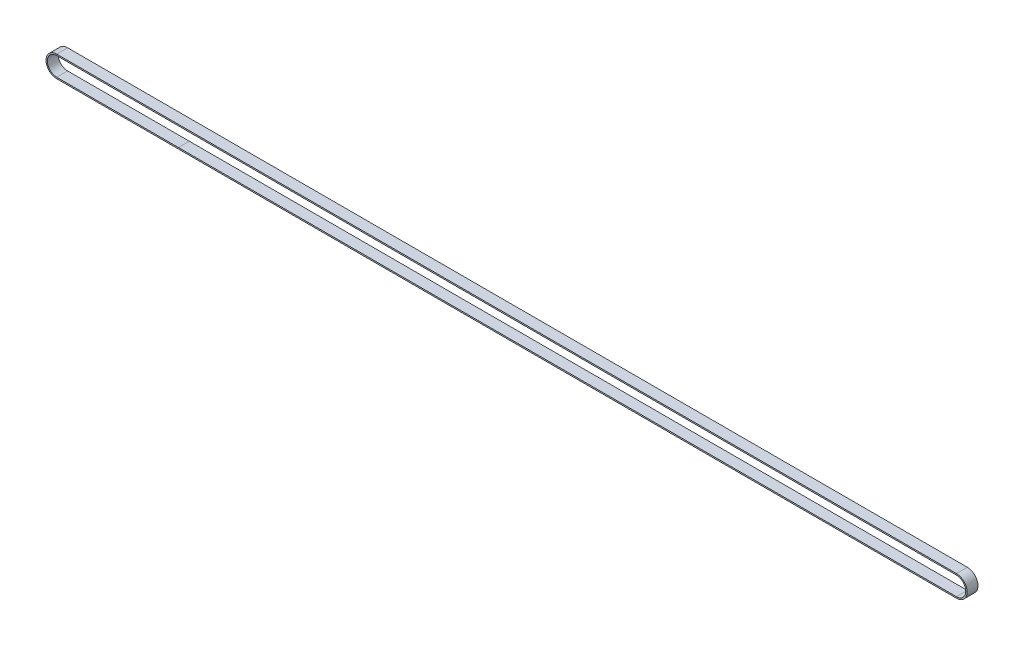
from build123d import *

# Parameters (mm, degrees)
BOSS_EXTRUDE1_DEPTH = 6
CUT_EXTRUDE_2_DEPTH = 7


with BuildPart() as part:
    # Sketch1 → Boss-Extrude1 (new body)
    with BuildSketch(Plane.XY):
        with BuildLine():
            Line((-149.09186475, 9.090711875), (346.90813525, 9.090711875))
            ThreePointArc((346.90813525, 9.090711875), (352.80813525, 3.190711875), (346.90813525, -2.709288125))
            Line((346.90813525, -2.709288125), (-149.09186475, -2.709288125))
            ThreePointArc((-149.09186475, -2.709288125), (-154.99186475, 3.190711875), (-149.09186475, 9.090711875))
        make_face()
        with BuildLine():
            Line((-148.86218671, -1.959304919), (-148.987691743, -1.959304919))
            ThreePointArc((-148.987691743, -1.959304919), (-154.24186475, 3.085711875), (-149.19686475, 8.340711875))
            Line((-149.19686475, 8.340711875), (-148.86218671, 8.34072867))
            ThreePointArc((-148.86218671, 8.34072867), (-148.782434101, 8.302805538), (-148.722766674, 8.237809494))
            ThreePointArc((-148.722766674, 8.237809494), (-148.665742437, 8.11963083), (-148.633605814, 7.992409772))
            ThreePointArc((-148.633605814, 7.992409772), (-148.030521792, 7.471711105), (-147.427440071, 7.992412438))
            ThreePointArc((-147.427440071, 7.992412438), (-147.395304056, 8.119633592), (-147.338280406, 8.237812478))
            ThreePointArc((-147.338280406, 8.237812478), (-147.278614273, 8.302808129), (-147.198941265, 8.340711875))
            Line((-147.198941265, 8.340711875), (-146.862186774, 8.34072867))
            ThreePointArc((-146.862186774, 8.34072867), (-146.782434165, 8.302805538), (-146.722766738, 8.237809494))
            ThreePointArc((-146.722766738, 8.237809494), (-146.665742501, 8.11963083), (-146.633605878, 7.992409772))
            ThreePointArc((-146.633605878, 7.992409772), (-146.030521856, 7.471711105), (-145.427440135, 7.992412438))
            ThreePointArc((-145.427440135, 7.992412438), (-145.395304121, 8.119633592), (-145.33828047, 8.237812478))
            ThreePointArc((-145.33828047, 8.237812478), (-145.278614337, 8.302808129), (-145.198941329, 8.340711875))
            Line((-145.198941329, 8.340711875), (-144.862186838, 8.34072867))
            ThreePointArc((-144.862186838, 8.34072867), (-144.78243423, 8.302805538), (-144.722766802, 8.237809494))
            ThreePointArc((-144.722766802, 8.237809494), (-144.665742565, 8.11963083), (-144.633605942, 7.992409772))
            ThreePointArc((-144.633605942, 7.992409772), (-144.03052192, 7.471711105), (-143.427440199, 7.992412438))
            ThreePointArc((-143.427440199, 7.992412438), (-143.395304185, 8.119633592), (-143.338280535, 8.237812478))
            ThreePointArc((-143.338280535, 8.237812478), (-143.278614401, 8.302808129), (-143.198941393, 8.340711875))
            Line((-143.198941393, 8.340711875), (-142.862186903, 8.34072867))
            ThreePointArc((-142.862186903, 8.34072867), (-142.782434294, 8.302805538), (-142.722766866, 8.237809494))
            ThreePointArc((-142.722766866, 8.237809494), (-142.665742629, 8.11963083), (-142.633606007, 7.992409772))
            ThreePointArc((-142.633606007, 7.992409772), (-142.030521984, 7.471711105), (-141.427440263, 7.992412438))
            ThreePointArc((-141.427440263, 7.992412438), (-141.395304249, 8.119633592), (-141.338280599, 8.237812478))
            ThreePointArc((-141.338280599, 8.237812478), (-141.278614465, 8.302808129), (-141.198941458, 8.340711875))
            Line((-141.198941458, 8.340711875), (-140.862186967, 8.34072867))
            ThreePointArc((-140.862186967, 8.34072867), (-140.782434358, 8.302805538), (-140.722766931, 8.237809494))
            ThreePointArc((-140.722766931, 8.237809494), (-140.665742694, 8.11963083), (-140.633606071, 7.992409772))
            ThreePointArc((-140.633606071, 7.992409772), (-140.030522048, 7.471711105), (-139.427440328, 7.992412438))
            ThreePointArc((-139.427440328, 7.992412438), (-139.395304313, 8.119633592), (-139.338280663, 8.237812478))
            ThreePointArc((-139.338280663, 8.237812478), (-139.27861453, 8.302808129), (-139.198941522, 8.340711875))
            Line((-139.198941522, 8.340711875), (-138.862187031, 8.34072867))
            ThreePointArc((-138.862187031, 8.34072867), (-138.782434422, 8.302805538), (-138.722766995, 8.237809494))
            ThreePointArc((-138.722766995, 8.237809494), (-138.665742758, 8.11963083), (-138.633606135, 7.992409772))
            ThreePointArc((-138.633606135, 7.992409772), (-138.030522113, 7.471711105), (-137.427440392, 7.992412438))
            ThreePointArc((-137.427440392, 7.992412438), (-137.395304377, 8.119633592), (-137.338280727, 8.237812478))
            ThreePointArc((-137.338280727, 8.237812478), (-137.278614594, 8.302808129), (-137.198941586, 8.340711875))
            Line((-137.198941586, 8.340711875), (-136.862187095, 8.34072867))
            ThreePointArc((-136.862187095, 8.34072867), (-136.782434486, 8.302805538), (-136.722767059, 8.237809494))
            ThreePointArc((-136.722767059, 8.237809494), (-136.665742822, 8.11963083), (-136.633606199, 7.992409772))
            ThreePointArc((-136.633606199, 7.992409772), (-136.030522177, 7.471711105), (-135.427440456, 7.992412438))
            ThreePointArc((-135.427440456, 7.992412438), (-135.395304442, 8.119633592), (-135.338280792, 8.237812478))
            ThreePointArc((-135.338280792, 8.237812478), (-135.278614658, 8.302808129), (-135.19894165, 8.340711875))
            Line((-135.19894165, 8.340711875), (-134.86218716, 8.34072867))
            ThreePointArc((-134.86218716, 8.34072867), (-134.782434551, 8.302805538), (-134.722767123, 8.237809494))
            ThreePointArc((-134.722767123, 8.237809494), (-134.665742886, 8.11963083), (-134.633606264, 7.992409772))
            ThreePointArc((-134.633606264, 7.992409772), (-134.030522241, 7.471711105), (-133.42744052, 7.992412438))
            ThreePointArc((-133.42744052, 7.992412438), (-133.395304506, 8.119633592), (-133.338280856, 8.237812478))
            ThreePointArc((-133.338280856, 8.237812478), (-133.278614722, 8.302808129), (-133.198941715, 8.340711875))
            Line((-133.198941715, 8.340711875), (-132.862187224, 8.34072867))
            ThreePointArc((-132.862187224, 8.34072867), (-132.782434615, 8.302805538), (-132.722767187, 8.237809494))
            ThreePointArc((-132.722767187, 8.237809494), (-132.665742951, 8.11963083), (-132.633606328, 7.992409772))
            ThreePointArc((-132.633606328, 7.992409772), (-132.030522305, 7.471711105), (-131.427440585, 7.992412438))
            ThreePointArc((-131.427440585, 7.992412438), (-131.39530457, 8.119633592), (-131.33828092, 8.237812478))
            ThreePointArc((-131.33828092, 8.237812478), (-131.278614786, 8.302808129), (-131.198941779, 8.340711875))
            Line((-131.198941779, 8.340711875), (-130.862187288, 8.34072867))
            ThreePointArc((-130.862187288, 8.34072867), (-130.782434679, 8.302805538), (-130.722767252, 8.237809494))
            ThreePointArc((-130.722767252, 8.237809494), (-130.665743015, 8.11963083), (-130.633606392, 7.992409772))
            ThreePointArc((-130.633606392, 7.992409772), (-130.03052237, 7.471711105), (-129.427440649, 7.992412438))
            ThreePointArc((-129.427440649, 7.992412438), (-129.395304634, 8.119633592), (-129.338280984, 8.237812478))
            ThreePointArc((-129.338280984, 8.237812478), (-129.278614851, 8.302808129), (-129.198941843, 8.340711875))
            Line((-129.198941843, 8.340711875), (-128.862187352, 8.34072867))
            ThreePointArc((-128.862187352, 8.34072867), (-128.782434743, 8.302805538), (-128.722767316, 8.237809494))
            ThreePointArc((-128.722767316, 8.237809494), (-128.665743079, 8.11963083), (-128.633606456, 7.992409772))
            ThreePointArc((-128.633606456, 7.992409772), (-128.030522434, 7.471711105), (-127.427440713, 7.992412438))
            ThreePointArc((-127.427440713, 7.992412438), (-127.395304699, 8.119633592), (-127.338281048, 8.237812478))
            ThreePointArc((-127.338281048, 8.237812478), (-127.278614915, 8.302808129), (-127.198941907, 8.340711875))
            Line((-127.198941907, 8.340711875), (-126.862187417, 8.34072867))
            ThreePointArc((-126.862187417, 8.34072867), (-126.782434808, 8.302805538), (-126.72276738, 8.237809494))
            ThreePointArc((-126.72276738, 8.237809494), (-126.665743143, 8.11963083), (-126.63360652, 7.992409772))
            ThreePointArc((-126.63360652, 7.992409772), (-126.030522498, 7.471711105), (-125.427440777, 7.992412438))
            ThreePointArc((-125.427440777, 7.992412438), (-125.395304763, 8.119633592), (-125.338281113, 8.237812478))
            ThreePointArc((-125.338281113, 8.237812478), (-125.278614979, 8.302808129), (-125.198941972, 8.340711875))
            Line((-125.198941972, 8.340711875), (-124.862187481, 8.34072867))
            ThreePointArc((-124.862187481, 8.34072867), (-124.782434872, 8.302805538), (-124.722767444, 8.237809494))
            ThreePointArc((-124.722767444, 8.237809494), (-124.665743208, 8.11963083), (-124.633606585, 7.992409772))
            ThreePointArc((-124.633606585, 7.992409772), (-124.030522562, 7.471711105), (-123.427440841, 7.992412438))
            ThreePointArc((-123.427440841, 7.992412438), (-123.395304827, 8.119633592), (-123.338281177, 8.237812478))
            ThreePointArc((-123.338281177, 8.237812478), (-123.278615043, 8.302808129), (-123.198942036, 8.340711875))
            Line((-123.198942036, 8.340711875), (-122.862187545, 8.34072867))
            ThreePointArc((-122.862187545, 8.34072867), (-122.782434936, 8.302805538), (-122.722767509, 8.237809494))
            ThreePointArc((-122.722767509, 8.237809494), (-122.665743272, 8.11963083), (-122.633606649, 7.992409772))
            ThreePointArc((-122.633606649, 7.992409772), (-122.030522627, 7.471711105), (-121.427440906, 7.992412438))
            ThreePointArc((-121.427440906, 7.992412438), (-121.395304891, 8.119633592), (-121.338281241, 8.237812478))
            ThreePointArc((-121.338281241, 8.237812478), (-121.278615108, 8.302808129), (-121.1989421, 8.340711875))
            Line((-121.1989421, 8.340711875), (-120.862187609, 8.34072867))
            ThreePointArc((-120.862187609, 8.34072867), (-120.782435, 8.302805538), (-120.722767573, 8.237809494))
            ThreePointArc((-120.722767573, 8.237809494), (-120.665743336, 8.11963083), (-120.633606713, 7.992409772))
            ThreePointArc((-120.633606713, 7.992409772), (-120.030522691, 7.471711105), (-119.42744097, 7.992412438))
            ThreePointArc((-119.42744097, 7.992412438), (-119.395304956, 8.119633592), (-119.338281305, 8.237812478))
            ThreePointArc((-119.338281305, 8.237812478), (-119.278615172, 8.302808129), (-119.198942164, 8.340711875))
            Line((-119.198942164, 8.340711875), (-118.862187673, 8.34072867))
            ThreePointArc((-118.862187673, 8.34072867), (-118.782435064, 8.302805538), (-118.722767637, 8.237809494))
            ThreePointArc((-118.722767637, 8.237809494), (-118.6657434, 8.11963083), (-118.633606777, 7.992409772))
            ThreePointArc((-118.633606777, 7.992409772), (-118.030522755, 7.471711105), (-117.427441034, 7.992412438))
            ThreePointArc((-117.427441034, 7.992412438), (-117.39530502, 8.119633592), (-117.33828137, 8.237812478))
            ThreePointArc((-117.33828137, 8.237812478), (-117.278615236, 8.302808129), (-117.198942228, 8.340711875))
            Line((-117.198942228, 8.340711875), (-116.862187738, 8.34072867))
            ThreePointArc((-116.862187738, 8.34072867), (-116.782435129, 8.302805538), (-116.722767701, 8.237809494))
            ThreePointArc((-116.722767701, 8.237809494), (-116.665743464, 8.11963083), (-116.633606842, 7.992409772))
            ThreePointArc((-116.633606842, 7.992409772), (-116.030522819, 7.471711105), (-115.427441098, 7.992412438))
            ThreePointArc((-115.427441098, 7.992412438), (-115.395305084, 8.119633592), (-115.338281434, 8.237812478))
            ThreePointArc((-115.338281434, 8.237812478), (-115.2786153, 8.302808129), (-115.198942293, 8.340711875))
            Line((-115.198942293, 8.340711875), (-114.862187802, 8.34072867))
            ThreePointArc((-114.862187802, 8.34072867), (-114.782435193, 8.302805538), (-114.722767766, 8.237809494))
            ThreePointArc((-114.722767766, 8.237809494), (-114.665743529, 8.11963083), (-114.633606906, 7.992409772))
            ThreePointArc((-114.633606906, 7.992409772), (-114.030522883, 7.471711105), (-113.427441163, 7.992412438))
            ThreePointArc((-113.427441163, 7.992412438), (-113.395305148, 8.119633592), (-113.338281498, 8.237812478))
            ThreePointArc((-113.338281498, 8.237812478), (-113.278615364, 8.302808129), (-113.198942357, 8.340711875))
            Line((-113.198942357, 8.340711875), (-112.862187866, 8.34072867))
            ThreePointArc((-112.862187866, 8.34072867), (-112.782435257, 8.302805538), (-112.72276783, 8.237809494))
            ThreePointArc((-112.72276783, 8.237809494), (-112.665743593, 8.11963083), (-112.63360697, 7.992409772))
            ThreePointArc((-112.63360697, 7.992409772), (-112.030522948, 7.471711105), (-111.427441227, 7.992412438))
            ThreePointArc((-111.427441227, 7.992412438), (-111.395305212, 8.119633592), (-111.338281562, 8.237812478))
            ThreePointArc((-111.338281562, 8.237812478), (-111.278615429, 8.302808129), (-111.198942421, 8.340711875))
            Line((-111.198942421, 8.340711875), (-110.86218793, 8.34072867))
            ThreePointArc((-110.86218793, 8.34072867), (-110.782435321, 8.302805538), (-110.722767894, 8.237809494))
            ThreePointArc((-110.722767894, 8.237809494), (-110.665743657, 8.11963083), (-110.633607034, 7.992409772))
            ThreePointArc((-110.633607034, 7.992409772), (-110.030523012, 7.471711105), (-109.427441291, 7.992412438))
            ThreePointArc((-109.427441291, 7.992412438), (-109.395305277, 8.119633592), (-109.338281627, 8.237812478))
            ThreePointArc((-109.338281627, 8.237812478), (-109.278615493, 8.302808129), (-109.198942485, 8.340711875))
            Line((-109.198942485, 8.340711875), (-108.862187995, 8.34072867))
            ThreePointArc((-108.862187995, 8.34072867), (-108.782435386, 8.302805538), (-108.722767958, 8.237809494))
            ThreePointArc((-108.722767958, 8.237809494), (-108.665743721, 8.11963083), (-108.633607098, 7.992409772))
            ThreePointArc((-108.633607098, 7.992409772), (-108.030523076, 7.471711105), (-107.427441355, 7.992412438))
            ThreePointArc((-107.427441355, 7.992412438), (-107.395305341, 8.119633592), (-107.338281691, 8.237812478))
            ThreePointArc((-107.338281691, 8.237812478), (-107.278615557, 8.302808129), (-107.19894255, 8.340711875))
            Line((-107.19894255, 8.340711875), (-106.862188059, 8.34072867))
            ThreePointArc((-106.862188059, 8.34072867), (-106.78243545, 8.302805538), (-106.722768022, 8.237809494))
            ThreePointArc((-106.722768022, 8.237809494), (-106.665743786, 8.11963083), (-106.633607163, 7.992409772))
            ThreePointArc((-106.633607163, 7.992409772), (-106.03052314, 7.471711105), (-105.42744142, 7.992412438))
            ThreePointArc((-105.42744142, 7.992412438), (-105.395305405, 8.119633592), (-105.338281755, 8.237812478))
            ThreePointArc((-105.338281755, 8.237812478), (-105.278615621, 8.302808129), (-105.198942614, 8.340711875))
            Line((-105.198942614, 8.340711875), (-104.862188123, 8.34072867))
            ThreePointArc((-104.862188123, 8.34072867), (-104.782435514, 8.302805538), (-104.722768087, 8.237809494))
            ThreePointArc((-104.722768087, 8.237809494), (-104.66574385, 8.11963083), (-104.633607227, 7.992409772))
            ThreePointArc((-104.633607227, 7.992409772), (-104.030523205, 7.471711105), (-103.427441484, 7.992412438))
            ThreePointArc((-103.427441484, 7.992412438), (-103.395305469, 8.119633592), (-103.338281819, 8.237812478))
            ThreePointArc((-103.338281819, 8.237812478), (-103.278615686, 8.302808129), (-103.198942678, 8.340711875))
            Line((-103.198942678, 8.340711875), (-102.862188187, 8.34072867))
            ThreePointArc((-102.862188187, 8.34072867), (-102.782435578, 8.302805538), (-102.722768151, 8.237809494))
            ThreePointArc((-102.722768151, 8.237809494), (-102.665743914, 8.11963083), (-102.633607291, 7.992409772))
            ThreePointArc((-102.633607291, 7.992409772), (-102.030523269, 7.471711105), (-101.427441548, 7.992412438))
            ThreePointArc((-101.427441548, 7.992412438), (-101.395305534, 8.119633592), (-101.338281883, 8.237812478))
            ThreePointArc((-101.338281883, 8.237812478), (-101.27861575, 8.302808129), (-101.198942742, 8.340711875))
            Line((-101.198942742, 8.340711875), (-100.862188251, 8.34072867))
            ThreePointArc((-100.862188251, 8.34072867), (-100.782435643, 8.302805538), (-100.722768215, 8.237809494))
            ThreePointArc((-100.722768215, 8.237809494), (-100.665743978, 8.11963083), (-100.633607355, 7.992409772))
            ThreePointArc((-100.633607355, 7.992409772), (-100.030523333, 7.471711105), (-99.427441612, 7.992412438))
            ThreePointArc((-99.427441612, 7.992412438), (-99.395305598, 8.119633592), (-99.338281948, 8.237812478))
            ThreePointArc((-99.338281948, 8.237812478), (-99.278615814, 8.302808129), (-99.198942806, 8.340711875))
            Line((-99.198942806, 8.340711875), (-98.862188316, 8.34072867))
            ThreePointArc((-98.862188316, 8.34072867), (-98.782435707, 8.302805538), (-98.722768279, 8.237809494))
            ThreePointArc((-98.722768279, 8.237809494), (-98.665744042, 8.11963083), (-98.63360742, 7.992409772))
            ThreePointArc((-98.63360742, 7.992409772), (-98.030523397, 7.471711105), (-97.427441676, 7.992412438))
            ThreePointArc((-97.427441676, 7.992412438), (-97.395305662, 8.119633592), (-97.338282012, 8.237812478))
            ThreePointArc((-97.338282012, 8.237812478), (-97.278615878, 8.302808129), (-97.198942871, 8.340711875))
            Line((-97.198942871, 8.340711875), (-96.86218838, 8.34072867))
            ThreePointArc((-96.86218838, 8.34072867), (-96.782435771, 8.302805538), (-96.722768344, 8.237809494))
            ThreePointArc((-96.722768344, 8.237809494), (-96.665744107, 8.11963083), (-96.633607484, 7.992409772))
            ThreePointArc((-96.633607484, 7.992409772), (-96.030523461, 7.471711105), (-95.427441741, 7.992412438))
            ThreePointArc((-95.427441741, 7.992412438), (-95.395305726, 8.119633592), (-95.338282076, 8.237812478))
            ThreePointArc((-95.338282076, 8.237812478), (-95.278615943, 8.302808129), (-95.198942935, 8.340711875))
            Line((-95.198942935, 8.340711875), (-94.862188444, 8.34072867))
            ThreePointArc((-94.862188444, 8.34072867), (-94.782435835, 8.302805538), (-94.722768408, 8.237809494))
            ThreePointArc((-94.722768408, 8.237809494), (-94.665744171, 8.11963083), (-94.633607548, 7.992409772))
            ThreePointArc((-94.633607548, 7.992409772), (-94.030523526, 7.471711105), (-93.427441805, 7.992412438))
            ThreePointArc((-93.427441805, 7.992412438), (-93.39530579, 8.119633592), (-93.33828214, 8.237812478))
            ThreePointArc((-93.33828214, 8.237812478), (-93.278616007, 8.302808129), (-93.198942999, 8.340711875))
            Line((-93.198942999, 8.340711875), (-92.862188508, 8.34072867))
            ThreePointArc((-92.862188508, 8.34072867), (-92.782435899, 8.302805538), (-92.722768472, 8.237809494))
            ThreePointArc((-92.722768472, 8.237809494), (-92.665744235, 8.11963083), (-92.633607612, 7.992409772))
            ThreePointArc((-92.633607612, 7.992409772), (-92.03052359, 7.471711105), (-91.427441869, 7.992412438))
            ThreePointArc((-91.427441869, 7.992412438), (-91.395305855, 8.119633592), (-91.338282205, 8.237812478))
            ThreePointArc((-91.338282205, 8.237812478), (-91.278616071, 8.302808129), (-91.198943063, 8.340711875))
            Line((-91.198943063, 8.340711875), (-90.862188573, 8.34072867))
            ThreePointArc((-90.862188573, 8.34072867), (-90.782435964, 8.302805538), (-90.722768536, 8.237809494))
            ThreePointArc((-90.722768536, 8.237809494), (-90.665744299, 8.11963083), (-90.633607677, 7.992409772))
            ThreePointArc((-90.633607677, 7.992409772), (-90.030523654, 7.471711105), (-89.427441933, 7.992412438))
            ThreePointArc((-89.427441933, 7.992412438), (-89.395305919, 8.119633592), (-89.338282269, 8.237812478))
            ThreePointArc((-89.338282269, 8.237812478), (-89.278616135, 8.302808129), (-89.198943128, 8.340711875))
            Line((-89.198943128, 8.340711875), (-88.862188637, 8.34072867))
            ThreePointArc((-88.862188637, 8.34072867), (-88.782436028, 8.302805538), (-88.7227686, 8.237809494))
            ThreePointArc((-88.7227686, 8.237809494), (-88.665744364, 8.11963083), (-88.633607741, 7.992409772))
            ThreePointArc((-88.633607741, 7.992409772), (-88.030523718, 7.471711105), (-87.427441998, 7.992412438))
            ThreePointArc((-87.427441998, 7.992412438), (-87.395305983, 8.119633592), (-87.338282333, 8.237812478))
            ThreePointArc((-87.338282333, 8.237812478), (-87.278616199, 8.302808129), (-87.198943192, 8.340711875))
            Line((-87.198943192, 8.340711875), (-86.862188701, 8.34072867))
            ThreePointArc((-86.862188701, 8.34072867), (-86.782436092, 8.302805538), (-86.722768665, 8.237809494))
            ThreePointArc((-86.722768665, 8.237809494), (-86.665744428, 8.11963083), (-86.633607805, 7.992409772))
            ThreePointArc((-86.633607805, 7.992409772), (-86.030523783, 7.471711105), (-85.427442062, 7.992412438))
            ThreePointArc((-85.427442062, 7.992412438), (-85.395306047, 8.119633592), (-85.338282397, 8.237812478))
            ThreePointArc((-85.338282397, 8.237812478), (-85.278616264, 8.302808129), (-85.198943256, 8.340711875))
            Line((-85.198943256, 8.340711875), (-84.862188765, 8.34072867))
            ThreePointArc((-84.862188765, 8.34072867), (-84.782436156, 8.302805538), (-84.722768729, 8.237809494))
            ThreePointArc((-84.722768729, 8.237809494), (-84.665744492, 8.11963083), (-84.633607869, 7.992409772))
            ThreePointArc((-84.633607869, 7.992409772), (-84.030523847, 7.471711105), (-83.427442126, 7.992412438))
            ThreePointArc((-83.427442126, 7.992412438), (-83.395306112, 8.119633592), (-83.338282461, 8.237812478))
            ThreePointArc((-83.338282461, 8.237812478), (-83.278616328, 8.302808129), (-83.19894332, 8.340711875))
            Line((-83.19894332, 8.340711875), (346.90813525, 8.340711875))
            ThreePointArc((346.90813525, 8.340711875), (352.05813525, 3.190711875), (346.90813525, -1.959288125))
            Line((346.90813525, -1.959288125), (-83.19894332, -1.959288125))
            ThreePointArc((-83.19894332, -1.959288125), (-83.278616328, -1.921384378), (-83.338282461, -1.856388727))
            ThreePointArc((-83.338282461, -1.856388727), (-83.395306112, -1.738209842), (-83.427442126, -1.610988687))
            ThreePointArc((-83.427442126, -1.610988687), (-84.030523847, -1.090287354), (-84.633607869, -1.610986021))
            ThreePointArc((-84.633607869, -1.610986021), (-84.665744492, -1.73820708), (-84.722768729, -1.856385743))
            ThreePointArc((-84.722768729, -1.856385743), (-84.782436156, -1.921381787), (-84.862188765, -1.959304919))
            Line((-84.862188765, -1.959304919), (-85.198943256, -1.959288125))
            ThreePointArc((-85.198943256, -1.959288125), (-85.278616264, -1.921384378), (-85.338282397, -1.856388727))
            ThreePointArc((-85.338282397, -1.856388727), (-85.395306047, -1.738209842), (-85.427442062, -1.610988687))
            ThreePointArc((-85.427442062, -1.610988687), (-86.030523783, -1.090287354), (-86.633607805, -1.610986021))
            ThreePointArc((-86.633607805, -1.610986021), (-86.665744428, -1.73820708), (-86.722768665, -1.856385743))
            ThreePointArc((-86.722768665, -1.856385743), (-86.782436092, -1.921381787), (-86.862188701, -1.959304919))
            Line((-86.862188701, -1.959304919), (-87.198943192, -1.959288125))
            ThreePointArc((-87.198943192, -1.959288125), (-87.278616199, -1.921384378), (-87.338282333, -1.856388727))
            ThreePointArc((-87.338282333, -1.856388727), (-87.395305983, -1.738209842), (-87.427441998, -1.610988687))
            ThreePointArc((-87.427441998, -1.610988687), (-88.030523718, -1.090287354), (-88.633607741, -1.610986021))
            ThreePointArc((-88.633607741, -1.610986021), (-88.665744364, -1.73820708), (-88.7227686, -1.856385743))
            ThreePointArc((-88.7227686, -1.856385743), (-88.782436028, -1.921381787), (-88.862188637, -1.959304919))
            Line((-88.862188637, -1.959304919), (-89.198943128, -1.959288125))
            ThreePointArc((-89.198943128, -1.959288125), (-89.278616135, -1.921384378), (-89.338282269, -1.856388727))
            ThreePointArc((-89.338282269, -1.856388727), (-89.395305919, -1.738209842), (-89.427441933, -1.610988687))
            ThreePointArc((-89.427441933, -1.610988687), (-90.030523654, -1.090287354), (-90.633607677, -1.610986021))
            ThreePointArc((-90.633607677, -1.610986021), (-90.665744299, -1.73820708), (-90.722768536, -1.856385743))
            ThreePointArc((-90.722768536, -1.856385743), (-90.782435964, -1.921381787), (-90.862188573, -1.959304919))
            Line((-90.862188573, -1.959304919), (-91.198943063, -1.959288125))
            ThreePointArc((-91.198943063, -1.959288125), (-91.278616071, -1.921384378), (-91.338282205, -1.856388727))
            ThreePointArc((-91.338282205, -1.856388727), (-91.395305855, -1.738209842), (-91.427441869, -1.610988687))
            ThreePointArc((-91.427441869, -1.610988687), (-92.03052359, -1.090287354), (-92.633607612, -1.610986021))
            ThreePointArc((-92.633607612, -1.610986021), (-92.665744235, -1.73820708), (-92.722768472, -1.856385743))
            ThreePointArc((-92.722768472, -1.856385743), (-92.782435899, -1.921381787), (-92.862188508, -1.959304919))
            Line((-92.862188508, -1.959304919), (-93.198942999, -1.959288125))
            ThreePointArc((-93.198942999, -1.959288125), (-93.278616007, -1.921384378), (-93.33828214, -1.856388727))
            ThreePointArc((-93.33828214, -1.856388727), (-93.39530579, -1.738209842), (-93.427441805, -1.610988687))
            ThreePointArc((-93.427441805, -1.610988687), (-94.030523526, -1.090287354), (-94.633607548, -1.610986021))
            ThreePointArc((-94.633607548, -1.610986021), (-94.665744171, -1.73820708), (-94.722768408, -1.856385743))
            ThreePointArc((-94.722768408, -1.856385743), (-94.782435835, -1.921381787), (-94.862188444, -1.959304919))
            Line((-94.862188444, -1.959304919), (-95.198942935, -1.959288125))
            ThreePointArc((-95.198942935, -1.959288125), (-95.278615943, -1.921384378), (-95.338282076, -1.856388727))
            ThreePointArc((-95.338282076, -1.856388727), (-95.395305726, -1.738209842), (-95.427441741, -1.610988687))
            ThreePointArc((-95.427441741, -1.610988687), (-96.030523461, -1.090287354), (-96.633607484, -1.610986021))
            ThreePointArc((-96.633607484, -1.610986021), (-96.665744107, -1.73820708), (-96.722768344, -1.856385743))
            ThreePointArc((-96.722768344, -1.856385743), (-96.782435771, -1.921381787), (-96.86218838, -1.959304919))
            Line((-96.86218838, -1.959304919), (-97.198942871, -1.959288125))
            ThreePointArc((-97.198942871, -1.959288125), (-97.278615878, -1.921384378), (-97.338282012, -1.856388727))
            ThreePointArc((-97.338282012, -1.856388727), (-97.395305662, -1.738209842), (-97.427441676, -1.610988687))
            ThreePointArc((-97.427441676, -1.610988687), (-98.030523397, -1.090287354), (-98.63360742, -1.610986021))
            ThreePointArc((-98.63360742, -1.610986021), (-98.665744042, -1.73820708), (-98.722768279, -1.856385743))
            ThreePointArc((-98.722768279, -1.856385743), (-98.782435707, -1.921381787), (-98.862188316, -1.959304919))
            Line((-98.862188316, -1.959304919), (-99.198942806, -1.959288125))
            ThreePointArc((-99.198942806, -1.959288125), (-99.278615814, -1.921384378), (-99.338281948, -1.856388727))
            ThreePointArc((-99.338281948, -1.856388727), (-99.395305598, -1.738209842), (-99.427441612, -1.610988687))
            ThreePointArc((-99.427441612, -1.610988687), (-100.030523333, -1.090287354), (-100.633607355, -1.610986021))
            ThreePointArc((-100.633607355, -1.610986021), (-100.665743978, -1.73820708), (-100.722768215, -1.856385743))
            ThreePointArc((-100.722768215, -1.856385743), (-100.782435643, -1.921381787), (-100.862188251, -1.959304919))
            Line((-100.862188251, -1.959304919), (-101.198942742, -1.959288125))
            ThreePointArc((-101.198942742, -1.959288125), (-101.27861575, -1.921384378), (-101.338281883, -1.856388727))
            ThreePointArc((-101.338281883, -1.856388727), (-101.395305534, -1.738209842), (-101.427441548, -1.610988687))
            ThreePointArc((-101.427441548, -1.610988687), (-102.030523269, -1.090287354), (-102.633607291, -1.610986021))
            ThreePointArc((-102.633607291, -1.610986021), (-102.665743914, -1.73820708), (-102.722768151, -1.856385743))
            ThreePointArc((-102.722768151, -1.856385743), (-102.782435578, -1.921381787), (-102.862188187, -1.959304919))
            Line((-102.862188187, -1.959304919), (-103.198942678, -1.959288125))
            ThreePointArc((-103.198942678, -1.959288125), (-103.278615686, -1.921384378), (-103.338281819, -1.856388727))
            ThreePointArc((-103.338281819, -1.856388727), (-103.395305469, -1.738209842), (-103.427441484, -1.610988687))
            ThreePointArc((-103.427441484, -1.610988687), (-104.030523205, -1.090287354), (-104.633607227, -1.610986021))
            ThreePointArc((-104.633607227, -1.610986021), (-104.66574385, -1.73820708), (-104.722768087, -1.856385743))
            ThreePointArc((-104.722768087, -1.856385743), (-104.782435514, -1.921381787), (-104.862188123, -1.959304919))
            Line((-104.862188123, -1.959304919), (-105.198942614, -1.959288125))
            ThreePointArc((-105.198942614, -1.959288125), (-105.278615621, -1.921384378), (-105.338281755, -1.856388727))
            ThreePointArc((-105.338281755, -1.856388727), (-105.395305405, -1.738209842), (-105.42744142, -1.610988687))
            ThreePointArc((-105.42744142, -1.610988687), (-106.03052314, -1.090287354), (-106.633607163, -1.610986021))
            ThreePointArc((-106.633607163, -1.610986021), (-106.665743786, -1.73820708), (-106.722768022, -1.856385743))
            ThreePointArc((-106.722768022, -1.856385743), (-106.78243545, -1.921381787), (-106.862188059, -1.959304919))
            Line((-106.862188059, -1.959304919), (-107.19894255, -1.959288125))
            ThreePointArc((-107.19894255, -1.959288125), (-107.278615557, -1.921384378), (-107.338281691, -1.856388727))
            ThreePointArc((-107.338281691, -1.856388727), (-107.395305341, -1.738209842), (-107.427441355, -1.610988687))
            ThreePointArc((-107.427441355, -1.610988687), (-108.030523076, -1.090287354), (-108.633607098, -1.610986021))
            ThreePointArc((-108.633607098, -1.610986021), (-108.665743721, -1.73820708), (-108.722767958, -1.856385743))
            ThreePointArc((-108.722767958, -1.856385743), (-108.782435386, -1.921381787), (-108.862187995, -1.959304919))
            Line((-108.862187995, -1.959304919), (-109.198942485, -1.959288125))
            ThreePointArc((-109.198942485, -1.959288125), (-109.278615493, -1.921384378), (-109.338281627, -1.856388727))
            ThreePointArc((-109.338281627, -1.856388727), (-109.395305277, -1.738209842), (-109.427441291, -1.610988687))
            ThreePointArc((-109.427441291, -1.610988687), (-110.030523012, -1.090287354), (-110.633607034, -1.610986021))
            ThreePointArc((-110.633607034, -1.610986021), (-110.665743657, -1.73820708), (-110.722767894, -1.856385743))
            ThreePointArc((-110.722767894, -1.856385743), (-110.782435321, -1.921381787), (-110.86218793, -1.959304919))
            Line((-110.86218793, -1.959304919), (-111.198942421, -1.959288125))
            ThreePointArc((-111.198942421, -1.959288125), (-111.278615429, -1.921384378), (-111.338281562, -1.856388727))
            ThreePointArc((-111.338281562, -1.856388727), (-111.395305212, -1.738209842), (-111.427441227, -1.610988687))
            ThreePointArc((-111.427441227, -1.610988687), (-112.030522948, -1.090287354), (-112.63360697, -1.610986021))
            ThreePointArc((-112.63360697, -1.610986021), (-112.665743593, -1.73820708), (-112.72276783, -1.856385743))
            ThreePointArc((-112.72276783, -1.856385743), (-112.782435257, -1.921381787), (-112.862187866, -1.959304919))
            Line((-112.862187866, -1.959304919), (-113.198942357, -1.959288125))
            ThreePointArc((-113.198942357, -1.959288125), (-113.278615364, -1.921384378), (-113.338281498, -1.856388727))
            ThreePointArc((-113.338281498, -1.856388727), (-113.395305148, -1.738209842), (-113.427441163, -1.610988687))
            ThreePointArc((-113.427441163, -1.610988687), (-114.030522883, -1.090287354), (-114.633606906, -1.610986021))
            ThreePointArc((-114.633606906, -1.610986021), (-114.665743529, -1.73820708), (-114.722767766, -1.856385743))
            ThreePointArc((-114.722767766, -1.856385743), (-114.782435193, -1.921381787), (-114.862187802, -1.959304919))
            Line((-114.862187802, -1.959304919), (-115.198942293, -1.959288125))
            ThreePointArc((-115.198942293, -1.959288125), (-115.2786153, -1.921384378), (-115.338281434, -1.856388727))
            ThreePointArc((-115.338281434, -1.856388727), (-115.395305084, -1.738209842), (-115.427441098, -1.610988687))
            ThreePointArc((-115.427441098, -1.610988687), (-116.030522819, -1.090287354), (-116.633606842, -1.610986021))
            ThreePointArc((-116.633606842, -1.610986021), (-116.665743464, -1.73820708), (-116.722767701, -1.856385743))
            ThreePointArc((-116.722767701, -1.856385743), (-116.782435129, -1.921381787), (-116.862187738, -1.959304919))
            Line((-116.862187738, -1.959304919), (-117.198942228, -1.959288125))
            ThreePointArc((-117.198942228, -1.959288125), (-117.278615236, -1.921384378), (-117.33828137, -1.856388727))
            ThreePointArc((-117.33828137, -1.856388727), (-117.39530502, -1.738209842), (-117.427441034, -1.610988687))
            ThreePointArc((-117.427441034, -1.610988687), (-118.030522755, -1.090287354), (-118.633606777, -1.610986021))
            ThreePointArc((-118.633606777, -1.610986021), (-118.6657434, -1.73820708), (-118.722767637, -1.856385743))
            ThreePointArc((-118.722767637, -1.856385743), (-118.782435064, -1.921381787), (-118.862187673, -1.959304919))
            Line((-118.862187673, -1.959304919), (-119.198942164, -1.959288125))
            ThreePointArc((-119.198942164, -1.959288125), (-119.278615172, -1.921384378), (-119.338281305, -1.856388727))
            ThreePointArc((-119.338281305, -1.856388727), (-119.395304956, -1.738209842), (-119.42744097, -1.610988687))
            ThreePointArc((-119.42744097, -1.610988687), (-120.030522691, -1.090287354), (-120.633606713, -1.610986021))
            ThreePointArc((-120.633606713, -1.610986021), (-120.665743336, -1.73820708), (-120.722767573, -1.856385743))
            ThreePointArc((-120.722767573, -1.856385743), (-120.782435, -1.921381787), (-120.862187609, -1.959304919))
            Line((-120.862187609, -1.959304919), (-121.1989421, -1.959288125))
            ThreePointArc((-121.1989421, -1.959288125), (-121.278615108, -1.921384378), (-121.338281241, -1.856388727))
            ThreePointArc((-121.338281241, -1.856388727), (-121.395304891, -1.738209842), (-121.427440906, -1.610988687))
            ThreePointArc((-121.427440906, -1.610988687), (-122.030522627, -1.090287354), (-122.633606649, -1.610986021))
            ThreePointArc((-122.633606649, -1.610986021), (-122.665743272, -1.73820708), (-122.722767509, -1.856385743))
            ThreePointArc((-122.722767509, -1.856385743), (-122.782434936, -1.921381787), (-122.862187545, -1.959304919))
            Line((-122.862187545, -1.959304919), (-123.198942036, -1.959288125))
            ThreePointArc((-123.198942036, -1.959288125), (-123.278615043, -1.921384378), (-123.338281177, -1.856388727))
            ThreePointArc((-123.338281177, -1.856388727), (-123.395304827, -1.738209842), (-123.427440841, -1.610988687))
            ThreePointArc((-123.427440841, -1.610988687), (-124.030522562, -1.090287354), (-124.633606585, -1.610986021))
            ThreePointArc((-124.633606585, -1.610986021), (-124.665743208, -1.73820708), (-124.722767444, -1.856385743))
            ThreePointArc((-124.722767444, -1.856385743), (-124.782434872, -1.921381787), (-124.862187481, -1.959304919))
            Line((-124.862187481, -1.959304919), (-125.198941972, -1.959288125))
            ThreePointArc((-125.198941972, -1.959288125), (-125.278614979, -1.921384378), (-125.338281113, -1.856388727))
            ThreePointArc((-125.338281113, -1.856388727), (-125.395304763, -1.738209842), (-125.427440777, -1.610988687))
            ThreePointArc((-125.427440777, -1.610988687), (-126.030522498, -1.090287354), (-126.63360652, -1.610986021))
            ThreePointArc((-126.63360652, -1.610986021), (-126.665743143, -1.73820708), (-126.72276738, -1.856385743))
            ThreePointArc((-126.72276738, -1.856385743), (-126.782434808, -1.921381787), (-126.862187417, -1.959304919))
            Line((-126.862187417, -1.959304919), (-127.198941907, -1.959288125))
            ThreePointArc((-127.198941907, -1.959288125), (-127.278614915, -1.921384378), (-127.338281048, -1.856388727))
            ThreePointArc((-127.338281048, -1.856388727), (-127.395304699, -1.738209842), (-127.427440713, -1.610988687))
            ThreePointArc((-127.427440713, -1.610988687), (-128.030522434, -1.090287354), (-128.633606456, -1.610986021))
            ThreePointArc((-128.633606456, -1.610986021), (-128.665743079, -1.73820708), (-128.722767316, -1.856385743))
            ThreePointArc((-128.722767316, -1.856385743), (-128.782434743, -1.921381787), (-128.862187352, -1.959304919))
            Line((-128.862187352, -1.959304919), (-129.198941843, -1.959288125))
            ThreePointArc((-129.198941843, -1.959288125), (-129.278614851, -1.921384378), (-129.338280984, -1.856388727))
            ThreePointArc((-129.338280984, -1.856388727), (-129.395304634, -1.738209842), (-129.427440649, -1.610988687))
            ThreePointArc((-129.427440649, -1.610988687), (-130.03052237, -1.090287354), (-130.633606392, -1.610986021))
            ThreePointArc((-130.633606392, -1.610986021), (-130.665743015, -1.73820708), (-130.722767252, -1.856385743))
            ThreePointArc((-130.722767252, -1.856385743), (-130.782434679, -1.921381787), (-130.862187288, -1.959304919))
            Line((-130.862187288, -1.959304919), (-131.198941779, -1.959288125))
            ThreePointArc((-131.198941779, -1.959288125), (-131.278614786, -1.921384378), (-131.33828092, -1.856388727))
            ThreePointArc((-131.33828092, -1.856388727), (-131.39530457, -1.738209842), (-131.427440585, -1.610988687))
            ThreePointArc((-131.427440585, -1.610988687), (-132.030522305, -1.090287354), (-132.633606328, -1.610986021))
            ThreePointArc((-132.633606328, -1.610986021), (-132.665742951, -1.73820708), (-132.722767187, -1.856385743))
            ThreePointArc((-132.722767187, -1.856385743), (-132.782434615, -1.921381787), (-132.862187224, -1.959304919))
            Line((-132.862187224, -1.959304919), (-133.198941715, -1.959288125))
            ThreePointArc((-133.198941715, -1.959288125), (-133.278614722, -1.921384378), (-133.338280856, -1.856388727))
            ThreePointArc((-133.338280856, -1.856388727), (-133.395304506, -1.738209842), (-133.42744052, -1.610988687))
            ThreePointArc((-133.42744052, -1.610988687), (-134.030522241, -1.090287354), (-134.633606264, -1.610986021))
            ThreePointArc((-134.633606264, -1.610986021), (-134.665742886, -1.73820708), (-134.722767123, -1.856385743))
            ThreePointArc((-134.722767123, -1.856385743), (-134.782434551, -1.921381787), (-134.86218716, -1.959304919))
            Line((-134.86218716, -1.959304919), (-135.19894165, -1.959288125))
            ThreePointArc((-135.19894165, -1.959288125), (-135.278614658, -1.921384378), (-135.338280792, -1.856388727))
            ThreePointArc((-135.338280792, -1.856388727), (-135.395304442, -1.738209842), (-135.427440456, -1.610988687))
            ThreePointArc((-135.427440456, -1.610988687), (-136.030522177, -1.090287354), (-136.633606199, -1.610986021))
            ThreePointArc((-136.633606199, -1.610986021), (-136.665742822, -1.73820708), (-136.722767059, -1.856385743))
            ThreePointArc((-136.722767059, -1.856385743), (-136.782434486, -1.921381787), (-136.862187095, -1.959304919))
            Line((-136.862187095, -1.959304919), (-137.198941586, -1.959288125))
            ThreePointArc((-137.198941586, -1.959288125), (-137.278614594, -1.921384378), (-137.338280727, -1.856388727))
            ThreePointArc((-137.338280727, -1.856388727), (-137.395304377, -1.738209842), (-137.427440392, -1.610988687))
            ThreePointArc((-137.427440392, -1.610988687), (-138.030522113, -1.090287354), (-138.633606135, -1.610986021))
            ThreePointArc((-138.633606135, -1.610986021), (-138.665742758, -1.73820708), (-138.722766995, -1.856385743))
            ThreePointArc((-138.722766995, -1.856385743), (-138.782434422, -1.921381787), (-138.862187031, -1.959304919))
            Line((-138.862187031, -1.959304919), (-139.198941522, -1.959288125))
            ThreePointArc((-139.198941522, -1.959288125), (-139.27861453, -1.921384378), (-139.338280663, -1.856388727))
            ThreePointArc((-139.338280663, -1.856388727), (-139.395304313, -1.738209842), (-139.427440328, -1.610988687))
            ThreePointArc((-139.427440328, -1.610988687), (-140.030522048, -1.090287354), (-140.633606071, -1.610986021))
            ThreePointArc((-140.633606071, -1.610986021), (-140.665742694, -1.73820708), (-140.722766931, -1.856385743))
            ThreePointArc((-140.722766931, -1.856385743), (-140.782434358, -1.921381787), (-140.862186967, -1.959304919))
            Line((-140.862186967, -1.959304919), (-141.198941458, -1.959288125))
            ThreePointArc((-141.198941458, -1.959288125), (-141.278614465, -1.921384378), (-141.338280599, -1.856388727))
            ThreePointArc((-141.338280599, -1.856388727), (-141.395304249, -1.738209842), (-141.427440263, -1.610988687))
            ThreePointArc((-141.427440263, -1.610988687), (-142.030521984, -1.090287354), (-142.633606007, -1.610986021))
            ThreePointArc((-142.633606007, -1.610986021), (-142.665742629, -1.73820708), (-142.722766866, -1.856385743))
            ThreePointArc((-142.722766866, -1.856385743), (-142.782434294, -1.921381787), (-142.862186903, -1.959304919))
            Line((-142.862186903, -1.959304919), (-143.198941393, -1.959288125))
            ThreePointArc((-143.198941393, -1.959288125), (-143.278614401, -1.921384378), (-143.338280535, -1.856388727))
            ThreePointArc((-143.338280535, -1.856388727), (-143.395304185, -1.738209842), (-143.427440199, -1.610988687))
            ThreePointArc((-143.427440199, -1.610988687), (-144.03052192, -1.090287354), (-144.633605942, -1.610986021))
            ThreePointArc((-144.633605942, -1.610986021), (-144.665742565, -1.73820708), (-144.722766802, -1.856385743))
            ThreePointArc((-144.722766802, -1.856385743), (-144.78243423, -1.921381787), (-144.862186838, -1.959304919))
            Line((-144.862186838, -1.959304919), (-145.198941329, -1.959288125))
            ThreePointArc((-145.198941329, -1.959288125), (-145.278614337, -1.921384378), (-145.33828047, -1.856388727))
            ThreePointArc((-145.33828047, -1.856388727), (-145.395304121, -1.738209842), (-145.427440135, -1.610988687))
            ThreePointArc((-145.427440135, -1.610988687), (-146.030521856, -1.090287354), (-146.633605878, -1.610986021))
            ThreePointArc((-146.633605878, -1.610986021), (-146.665742501, -1.73820708), (-146.722766738, -1.856385743))
            ThreePointArc((-146.722766738, -1.856385743), (-146.782434165, -1.921381787), (-146.862186774, -1.959304919))
            Line((-146.862186774, -1.959304919), (-147.198941265, -1.959288125))
            ThreePointArc((-147.198941265, -1.959288125), (-147.278614273, -1.921384378), (-147.338280406, -1.856388727))
            ThreePointArc((-147.338280406, -1.856388727), (-147.395304056, -1.738209842), (-147.427440071, -1.610988687))
            ThreePointArc((-147.427440071, -1.610988687), (-148.030521792, -1.090287354), (-148.633605814, -1.610986021))
            ThreePointArc((-148.633605814, -1.610986021), (-148.665742437, -1.73820708), (-148.722766674, -1.856385743))
            ThreePointArc((-148.722766674, -1.856385743), (-148.782434101, -1.921381787), (-148.86218671, -1.959304919))
        make_face(mode=Mode.SUBTRACT)
    extrude(amount=BOSS_EXTRUDE1_DEPTH)

    # 草图1 → 切除-拉伸2 (cut, through all)
    with BuildSketch(Plane.XY.offset(6)):
        Polygon((-81.966358792, 8.340711875), (-149.19686475, 8.340711875), (-149.09186475, -1.960358402), (-81.966358792, -1.959288125), align=None)
    extrude(amount=-CUT_EXTRUDE_2_DEPTH, mode=Mode.SUBTRACT)


solid = part.part
